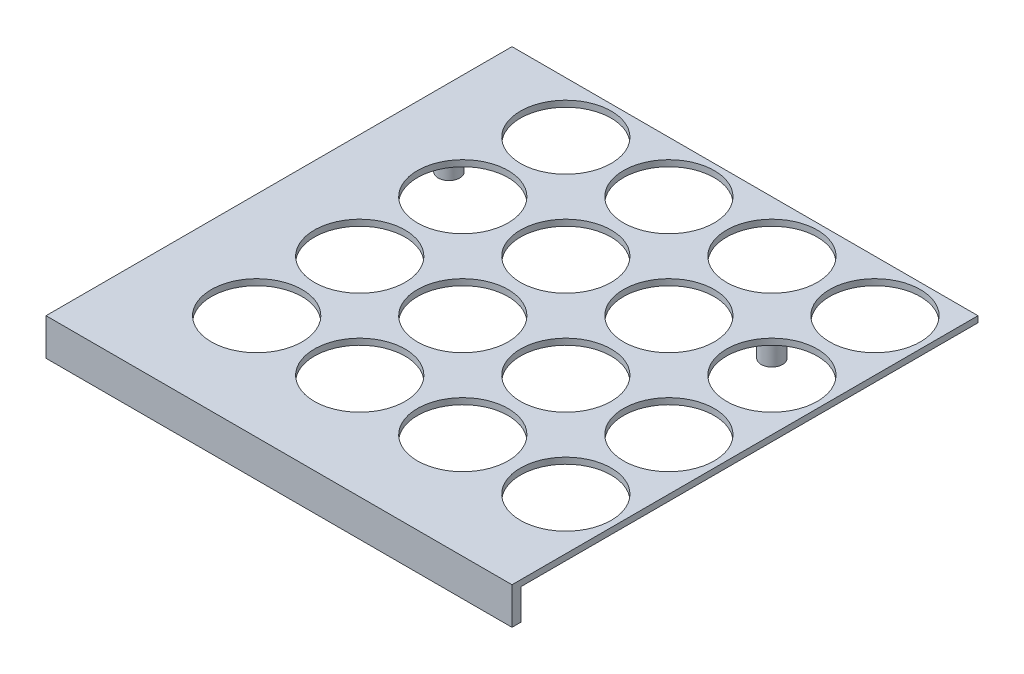
from build123d import *

# Parameters (mm, degrees)
SKETCH1_W            = 151.5
SKETCH1_H            = 151.5
BOSS_EXTRUDE1_DEPTH  = 2
SKETCH2_R            = 14.75
CUT_EXTRUDE2_DEPTH   = 2
LPATTERN1_COUNT      = 4
LPATTERN1_PITCH      = 33.5
LPATTERN1_COUNT_DIR2 = 4
LPATTERN1_PITCH_DIR2 = 33.5
SKETCH3_W            = 151.5
SKETCH3_H            = 151.5
BOSS_EXTRUDE2_DEPTH  = 10
SKETCH5_W            = 148.5
SKETCH5_H            = 148.5
CUT_EXTRUDE4_DEPTH   = 10
SKETCH8_R            = 3.5
BOSS_EXTRUDE4_DEPTH  = 10
LPATTERN2_COUNT      = 2
LPATTERN2_PITCH      = 105
LPATTERN2_COUNT_DIR2 = 2
LPATTERN2_PITCH_DIR2 = 105


with BuildPart() as part:
    # Sketch1 → Boss-Extrude1 (new body)
    with BuildSketch(Plane(origin=(0, 0, 0), x_dir=(1, 0, 0), z_dir=(0, 1, 0))):
        with Locations((75.75, 75.75)):
            Rectangle(SKETCH1_W, SKETCH1_H)
    extrude(amount=BOSS_EXTRUDE1_DEPTH)

    # Sketch2 → Cut-Extrude2 (cut)
    with BuildSketch(Plane(origin=(0, 0, 0), x_dir=(1, 0, 0), z_dir=(0, 1, 0))):
        with Locations((34.25, 34.25)):
            Circle(SKETCH2_R)
    cut_extrude2 = extrude(amount=CUT_EXTRUDE2_DEPTH, mode=Mode.SUBTRACT)

    # LPattern1: Cut-Extrude2 4 × 4
    with Locations(*[(i * LPATTERN1_PITCH, 0, -j * LPATTERN1_PITCH_DIR2) for i in range(LPATTERN1_COUNT) for j in range(LPATTERN1_COUNT_DIR2) if (i, j) != (0, 0)]):
        add(cut_extrude2, mode=Mode.SUBTRACT)

    # Sketch3 → Boss-Extrude2 (add)
    with BuildSketch(Plane(origin=(0, 0, 0), x_dir=(1, 0, 0), z_dir=(0, 1, 0))):
        with Locations((75.75, 75.75)):
            Rectangle(SKETCH3_W, SKETCH3_H)
    extrude(amount=-BOSS_EXTRUDE2_DEPTH)

    # Sketch5 → Cut-Extrude4 (cut)
    with BuildSketch(Plane(origin=(0, 0, 0), x_dir=(1, 0, 0), z_dir=(0, 1, 0))):
        with Locations((77.25, 77.25)):
            Rectangle(SKETCH5_W, SKETCH5_H)
    extrude(amount=-CUT_EXTRUDE4_DEPTH, mode=Mode.SUBTRACT)

    # Sketch8 → Boss-Extrude4 (add)
    with BuildSketch(Plane(origin=(0, 0, 0), x_dir=(1, 0, 0), z_dir=(0, 1, 0))):
        with Locations((13, 13)):
            Circle(SKETCH8_R)
    boss_extrude4 = extrude(amount=-BOSS_EXTRUDE4_DEPTH)

    # LPattern2: Boss-Extrude4 2 × 2
    with Locations(*[(j * LPATTERN2_PITCH_DIR2, 0, -i * LPATTERN2_PITCH) for i in range(LPATTERN2_COUNT) for j in range(LPATTERN2_COUNT_DIR2) if (i, j) != (0, 0)]):
        add(boss_extrude4)


solid = part.part
